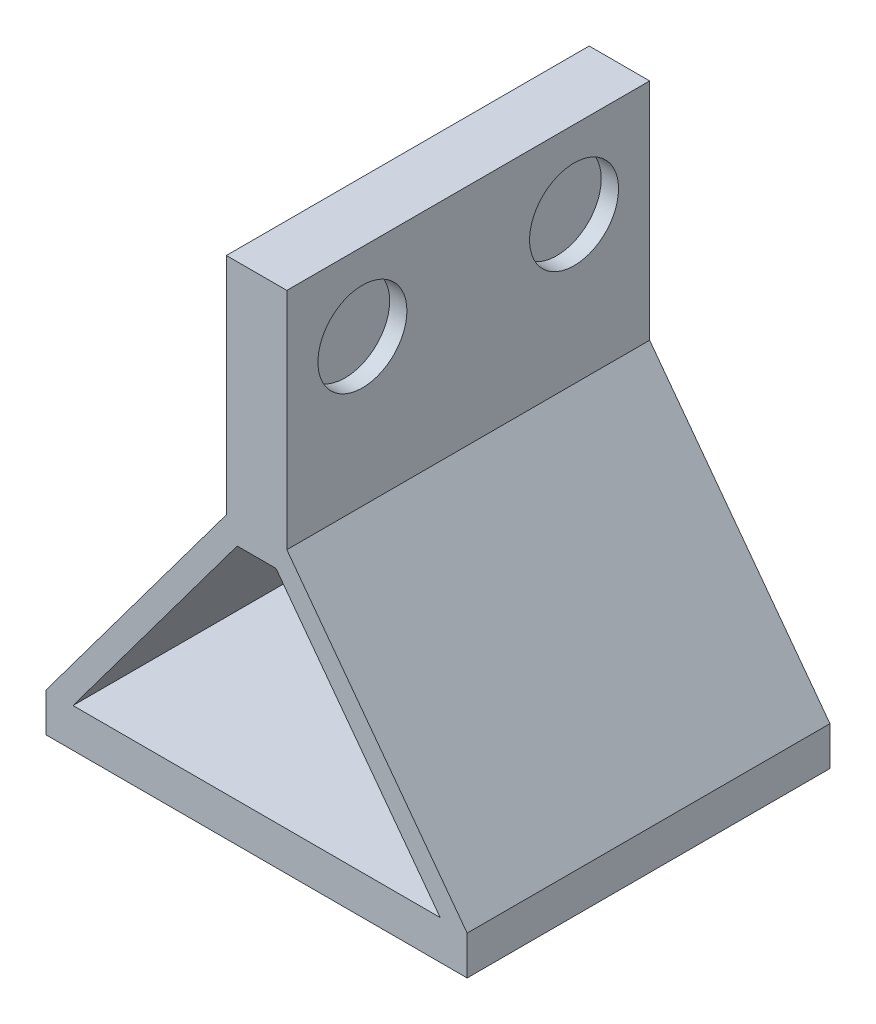
from build123d import *

# Parameters (mm, degrees)
BOSS_EXTRUDE1_DEPTH = 42
SKETCH2_W           = 7
SKETCH2_H           = 26
BOSS_EXTRUDE2_DEPTH = 42
SKETCH3_R           = 5.15
CUT_EXTRUDE1_DEPTH  = 2
SKETCH4_R           = 3.25
BOSS_EXTRUDE3_DEPTH = 7
SKETCH5_W           = 48.75
SKETCH5_H           = 2
BOSS_EXTRUDE4_DEPTH = 42


with BuildPart() as part:
    # Sketch1 → Boss-Extrude1 (new body)
    with BuildSketch(Plane.XY):
        Polygon((-24.92211838, -2.484423676), (-24.92211838, -4.984423676), (23.82788162, -4.984423676), (23.82788162, -2.484423676), (2.95288162, 25.515576324), (-4.04711838, 25.515576324), align=None)
        Polygon((-21.803802026, -2.484423676), (-2.792641312, 23.015576324), (1.698404552, 23.015576324), (20.709565266, -2.484423676), align=None, mode=Mode.SUBTRACT)
    extrude(amount=BOSS_EXTRUDE1_DEPTH)

    # Sketch2 → Boss-Extrude2 (add)
    with BuildSketch(Plane.XY.offset(42)):
        with Locations((-0.54711838, 38.515576324)):
            Rectangle(SKETCH2_W, SKETCH2_H)
    extrude(amount=-BOSS_EXTRUDE2_DEPTH)

    # Sketch3 → Cut-Extrude1 (cut)
    with BuildSketch(Plane(origin=(2.95288162, 0, 0), x_dir=(0, 0, -1), z_dir=(1, 0, 0))):
        with Locations((-33.25, 42.515576324)):
            Circle(SKETCH3_R)
        with Locations((-8.75, 42.515576324)):
            Circle(SKETCH3_R)
    extrude(amount=-CUT_EXTRUDE1_DEPTH, mode=Mode.SUBTRACT)

    # Sketch4 → Boss-Extrude3 (add)
    with BuildSketch(Plane.XZ.offset(4.984423676)):
        with Locations((-12.92211838, 33.4)):
            Circle(SKETCH4_R)
        with Locations((11.87788162, 33.4)):
            Circle(SKETCH4_R)
        with Locations((11.87788162, 8.6)):
            Circle(SKETCH4_R)
        with Locations((-12.92211838, 8.6)):
            Circle(SKETCH4_R)
    extrude(amount=BOSS_EXTRUDE3_DEPTH)

    # Sketch5 → Boss-Extrude4 (add)
    with BuildSketch(Plane.XY.offset(42)):
        with Locations((-0.54711838, -5.984423676)):
            Rectangle(SKETCH5_W, SKETCH5_H)
    extrude(amount=-BOSS_EXTRUDE4_DEPTH)


solid = part.part
